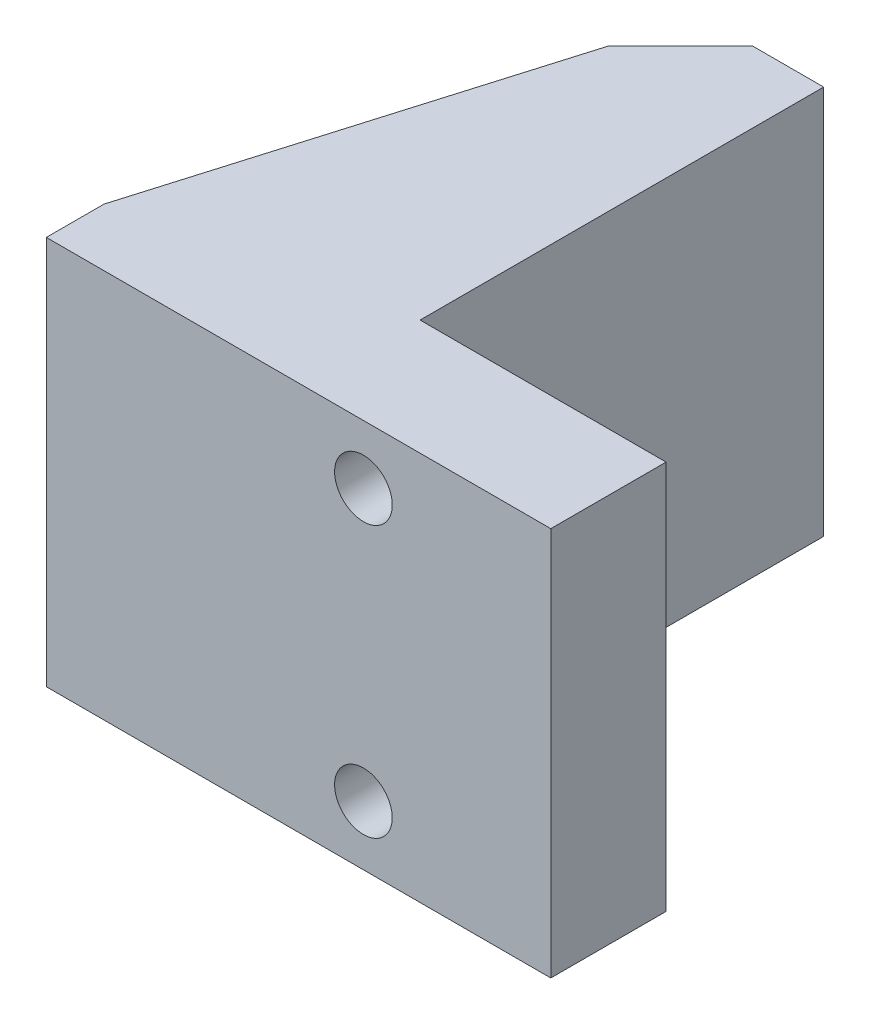
from build123d import *

# Parameters (mm, degrees)
SKETCH1_W           = 17.145
SKETCH1_H           = 17.145
BOSS_EXTRUDE1_DEPTH = 5.08
SKETCH2_R           = 1.27
CUT_EXTRUDE1_DEPTH  = 6.08
SKETCH3_R           = 2.54
CUT_EXTRUDE4_DEPTH  = 2.54
SKETCH4_W           = 6.307704678
SKETCH4_H           = 17.145
BOSS_EXTRUDE2_DEPTH = 17.78
SKETCH5_W           = 2.54
SKETCH5_H           = 17.145
BOSS_EXTRUDE3_DEPTH = 5.08
CHAMFER1_SIZE       = 3.175
BOSS_EXTRUDE4_DEPTH = 2.54
BOSS_EXTRUDE5_DEPTH = 2.54


with BuildPart() as part:
    # Sketch1 → Boss-Extrude1 (new body)
    with BuildSketch(Plane.XY):
        with Locations((8.5725, -8.5725)):
            Rectangle(SKETCH1_W, SKETCH1_H)
    extrude(amount=BOSS_EXTRUDE1_DEPTH)

    # Sketch2 → Cut-Extrude1 (cut, through all)
    with BuildSketch(Plane(origin=(0, 0, 0), x_dir=(-1, 0, 0), z_dir=(0, 0, -1))):
        with Locations((-8.89, -2.5908)):
            Circle(SKETCH2_R)
        with Locations((-8.89, -14.5288)):
            Circle(SKETCH2_R)
    extrude(amount=-CUT_EXTRUDE1_DEPTH, mode=Mode.SUBTRACT)

    # Sketch3 → Cut-Extrude4 (cut)
    with BuildSketch(Plane(origin=(0, 0, 0), x_dir=(-1, 0, 0), z_dir=(0, 0, -1))):
        with Locations((-8.89, -2.5908)):
            Circle(SKETCH3_R)
        with Locations((-8.89, -14.5288)):
            Circle(SKETCH3_R)
    extrude(amount=-CUT_EXTRUDE4_DEPTH, mode=Mode.SUBTRACT)

    # Sketch4 → Boss-Extrude2 (add)
    with BuildSketch(Plane(origin=(0, 0, 0), x_dir=(-1, 0, 0), z_dir=(0, 0, -1))):
        with Locations((-3.153852339, -8.5725)):
            Rectangle(SKETCH4_W, SKETCH4_H)
    extrude(amount=BOSS_EXTRUDE2_DEPTH)

    # Sketch5 → Boss-Extrude3 (add)
    with BuildSketch(Plane.ZY):
        with Locations((3.81, -8.5725)):
            Rectangle(SKETCH5_W, SKETCH5_H)
    extrude(amount=BOSS_EXTRUDE3_DEPTH)

    # Chamfer1
    chamfer1_edges = [part.edges().sort_by_distance(p)[0] for p in [
        (0, -8.5725, -17.78),
    ]]
    chamfer(chamfer1_edges, length=CHAMFER1_SIZE)

    # Sketch7 → Boss-Extrude4 (add)
    with BuildSketch(Plane(origin=(0, 0, 0), x_dir=(1, 0, 0), z_dir=(0, 1, 0))):
        Polygon((-5.08, -2.54), (0, 14.605), (0, -2.54), align=None)
    extrude(amount=-BOSS_EXTRUDE4_DEPTH)

    # Sketch8 → Boss-Extrude5 (add)
    with BuildSketch(Plane.XZ.offset(17.145)):
        Polygon((0, 2.54), (-5.08, 2.54), (0, -14.605), align=None)
    extrude(amount=-BOSS_EXTRUDE5_DEPTH)


solid = part.part
